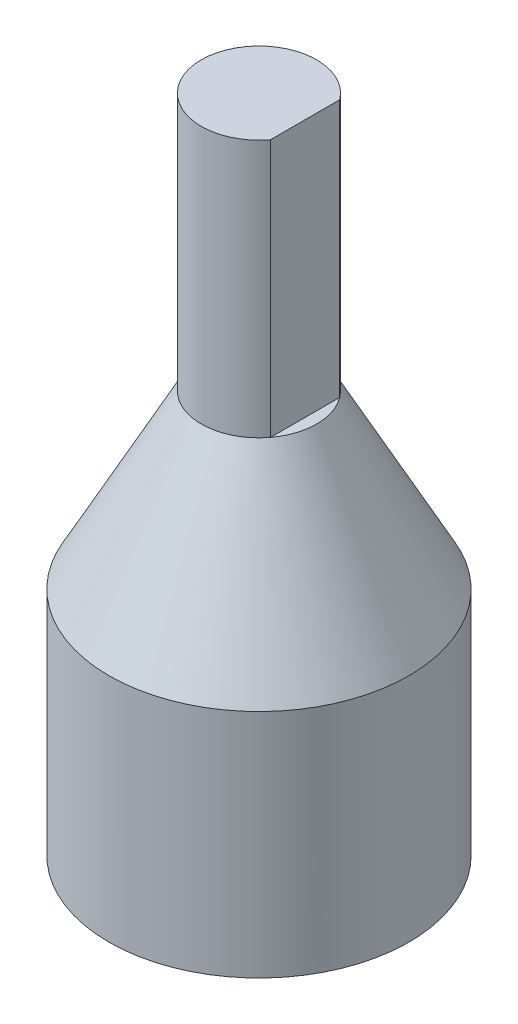
from build123d import *

# Parameters (mm, degrees)
SKETCH1_R               = 8.255
BOSS_EXTRUDE1_DEPTH     = 12.7
SKETCH6_W               = 0.635
SKETCH6_H               = 14.1852904
CUT_EXTRUDE3_DEPTH      = 12.7
CUT_EXTRUDE3_DEPTH_BACK = 12.7


with BuildPart() as part:
    # Sketch1 → Boss-Extrude1 (new body)
    with BuildSketch(Plane(origin=(0, 0, 0), x_dir=(1, 0, 0), z_dir=(0, 1, 0))):
        with Locations((4.445, 5.08)):
            Circle(SKETCH1_R)
        Polygon((4.445, 0), (9.525, 0), (9.525, 10.16), (-0.635, 10.16), (-0.635, 0), align=None, mode=Mode.SUBTRACT)
    extrude(amount=BOSS_EXTRUDE1_DEPTH)

    # Sketch5 → Revolve4 (revolve)
    with BuildSketch(Plane(origin=(0, 0, -5.08), x_dir=(-1, 0, 0), z_dir=(0, 0, -1))):
        Polygon((-12.7, 12.7), (-4.445, 12.7), (-4.445, 20.246092455), (-4.445, 36.336009477), (-7.62, 36.336009477), (-7.62, 22.150719077), align=None)
    revolve(axis=Axis((4.445, 36.336009477, -5.08), (0, 1, 0)))

    # Sketch6 → Cut-Extrude3 (cut, two sides)
    with BuildSketch(Plane(origin=(0, 0, -5.08), x_dir=(-1, 0, 0), z_dir=(0, 0, -1))) as cut_extrude3_sk:
        with Locations((-7.3025, 29.243364277)):
            Rectangle(SKETCH6_W, SKETCH6_H)
    extrude(amount=CUT_EXTRUDE3_DEPTH, mode=Mode.SUBTRACT)
    extrude(cut_extrude3_sk.sketch, amount=-CUT_EXTRUDE3_DEPTH_BACK, mode=Mode.SUBTRACT)


solid = part.part
